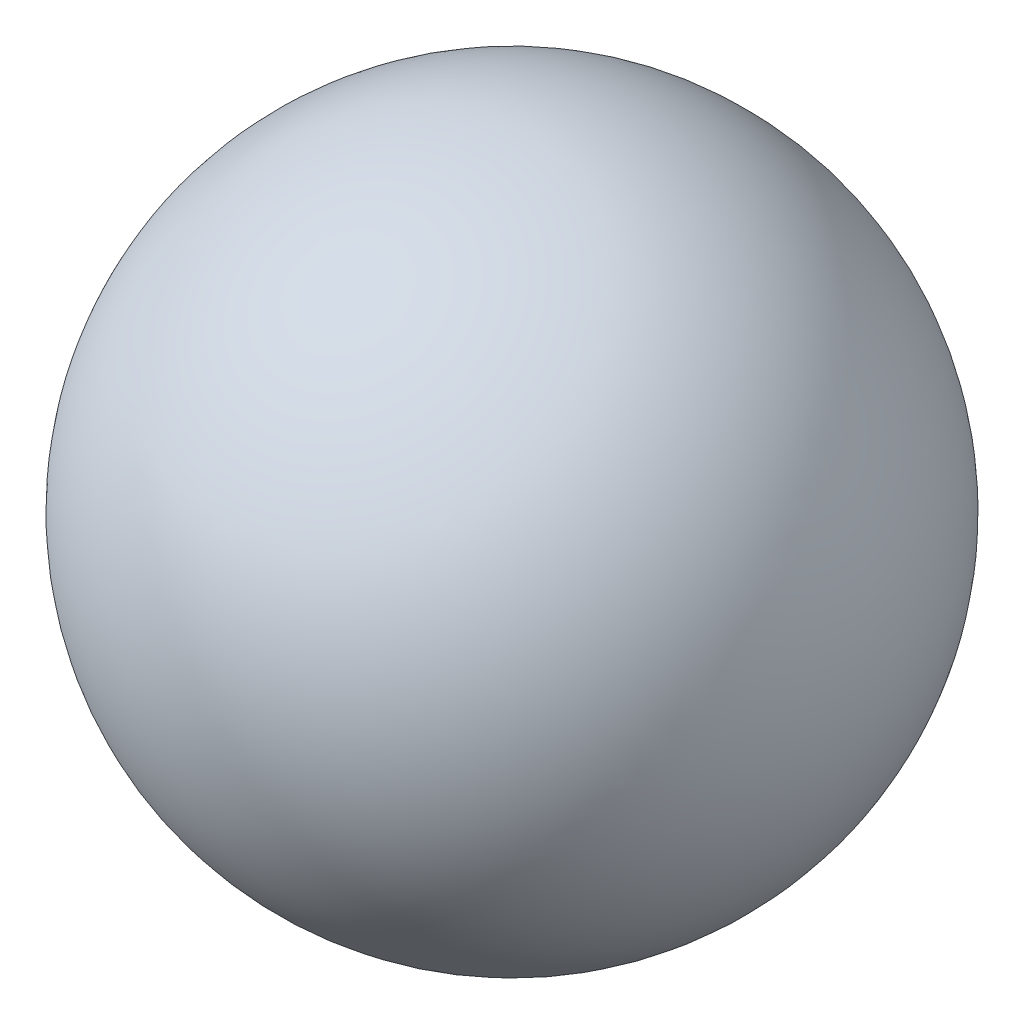
from build123d import *


with BuildPart() as part:
    # Sketch1 → Revolve1 (revolve)
    with BuildSketch(Plane(origin=(0, 0, 0), x_dir=(1, 0, 0), z_dir=(0, 1, 0))):
        with BuildLine():
            Line((0, 0), (-400, 0))
            ThreePointArc((-400, 0), (-200, 200), (0, 0))
        make_face()
    revolve(axis=Axis((0, 0, 0), (-1, 0, 0)))


solid = part.part
